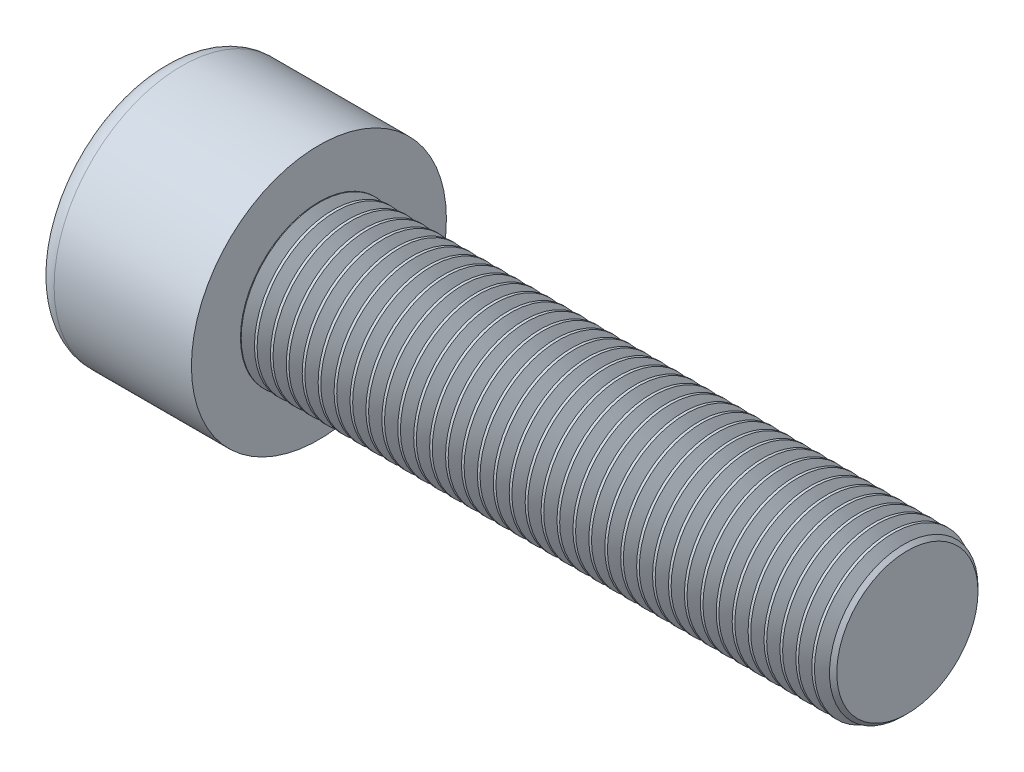
from build123d import *

# Parameters (mm, degrees)
SKETCH1_R           = 6.5
BASEHEAD_DEPTH      = 8
SKETCH2_R           = 4
BASEBODY_DEPTH      = 30
HEXAGONSOCKET_DEPTH = 4
TOPFILLET_R         = 1
CHAMFER1_SIZE       = 0.4
LPATTERN10_COUNT    = 37
LPATTERN10_PITCH    = 0.8118


with BuildPart() as part:
    # Sketch1 → BaseHead (new body)
    with BuildSketch(Plane(origin=(0, 0, 0), x_dir=(0, 0, -1), z_dir=(1, 0, 0))):
        Circle(SKETCH1_R)
    extrude(amount=BASEHEAD_DEPTH)

    # Sketch2 → BaseBody (add)
    with BuildSketch(Plane(origin=(8, 0, 0), x_dir=(0, 0, -1), z_dir=(1, 0, 0))):
        Circle(SKETCH2_R)
    extrude(amount=BASEBODY_DEPTH)

    # Sketch3 → HexagonSocket (cut)
    with BuildSketch(Plane(origin=(0, 0, 0), x_dir=(0, 0, -1), z_dir=(1, 0, 0))):
        Polygon((3.464101615, 0), (1.732050808, 3), (-1.732050808, 3), (-3.464101615, 0), (-1.732050808, -3), (1.732050808, -3), align=None)
    extrude(amount=HEXAGONSOCKET_DEPTH, mode=Mode.SUBTRACT)

    # Sketch4 → Cut-Revolve1 (revolve, cut)
    with BuildSketch(Plane(origin=(-4.19613823, 0.75, 0), x_dir=(-1, 0, 0), z_dir=(0, 0, 1))):
        Polygon((-8.19613823, 3.75), (-9.928189037, 0.75), (-8.19613823, 0.75), align=None)
    revolve(axis=Axis((0.838992387, 0, 0), (-1, 0, 0)), mode=Mode.SUBTRACT)

    # TopFillet
    topfillet_edges = [part.edges().sort_by_distance(p)[0] for p in [
        (0, 0, 6.5),
    ]]
    fillet(topfillet_edges, radius=TOPFILLET_R)

    # Chamfer1
    chamfer1_edges = [part.edges().sort_by_distance(p)[0] for p in [
        (38, 0, 4),
    ]]
    chamfer(chamfer1_edges, length=CHAMFER1_SIZE)

    # Sketch5 → Cut-Revolve10 (revolve, cut)
    with BuildSketch(Plane.XY):
        Polygon((37.6, 3.414133814), (37.93825, 4), (37.93825, 4.6765), (37.26175, 4.6765), (37.26175, 4), align=None)
    cut_revolve10 = revolve(axis=Axis((0, 0, 0), (1, 0, 0)), mode=Mode.SUBTRACT)

    # LPattern10: Cut-Revolve10 ×37
    with Locations(*[(-i * LPATTERN10_PITCH, 0, 0) for i in range(1, LPATTERN10_COUNT)]):
        add(cut_revolve10, mode=Mode.SUBTRACT)


solid = part.part
